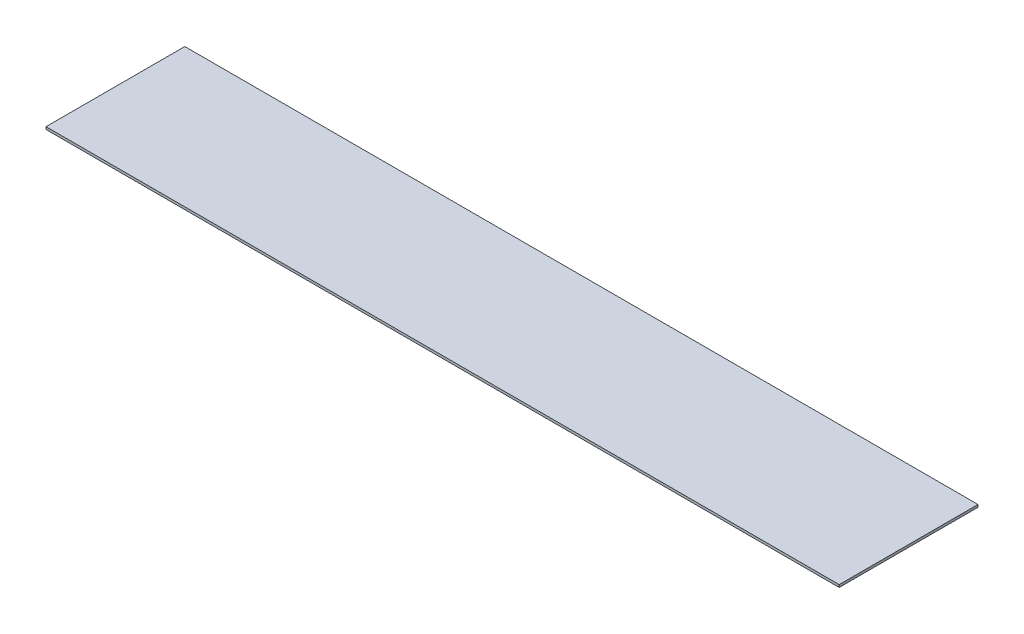
from build123d import *

# Parameters (mm, degrees)
SKETCH1_W           = 508
SKETCH1_H           = 88.9
BOSS_EXTRUDE1_DEPTH = 1.5875


with BuildPart() as part:
    # Sketch1 → Boss-Extrude1 (new body)
    with BuildSketch(Plane(origin=(0, 0, 0), x_dir=(1, 0, 0), z_dir=(0, 1, 0))):
        Rectangle(SKETCH1_W, SKETCH1_H)
    extrude(amount=BOSS_EXTRUDE1_DEPTH)


solid = part.part
